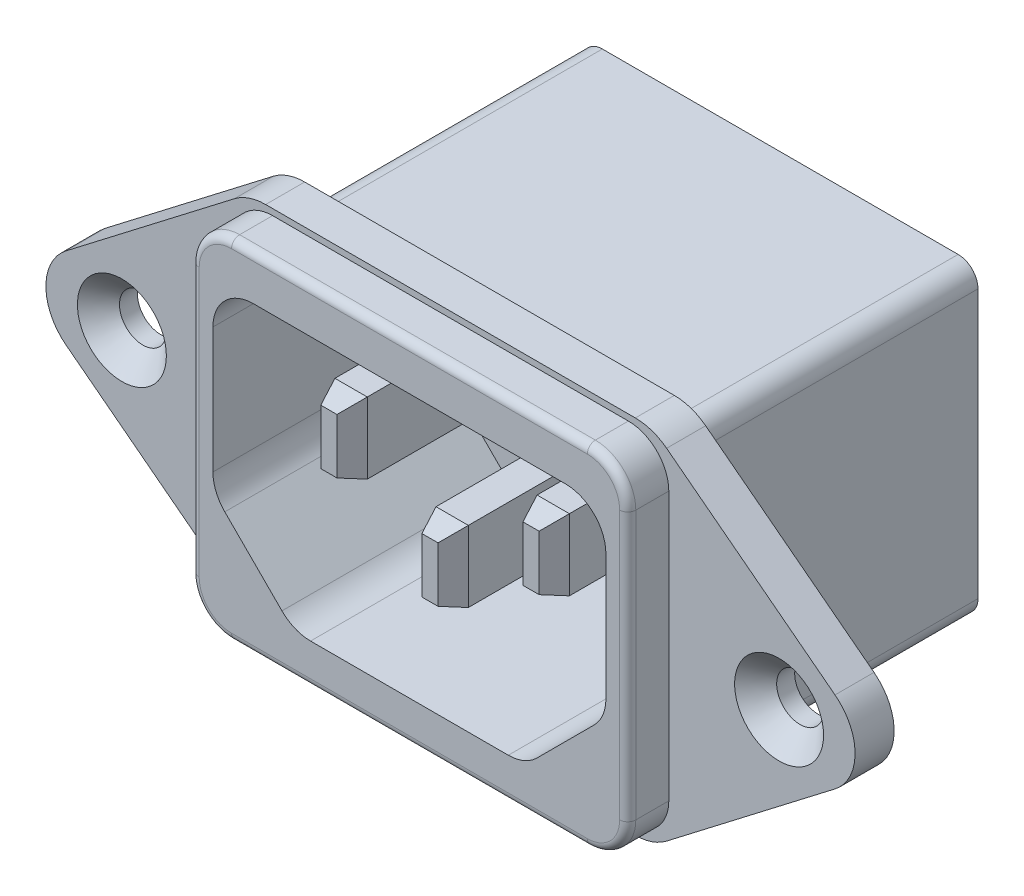
from build123d import *

# Parameters (mm, degrees)
EXTRUDE1_DEPTH                                    = 5.15
FILLET1_R                                         = 1
EXTRUDE2_DEPTH                                    = 17.78
EXTRUDE3_DEPTH                                    = 13.97
EXTRUDE4_DEPTH                                    = 3.81
FILLET2_R                                         = 2.5
SKETCH5_W                                         = 2
SKETCH5_H                                         = 4.4
EXTRUDE5_DEPTH                                    = 12.7
CHAMFER1_SIZE                                     = 0.5
CHAMFER1_SIZE2                                    = 1.37373871
CHAMFER1_PART_2_SIZE                              = 0.5
CHAMFER1_PART_2_SIZE2                             = 1.37373871
CHAMFER1_PART_3_SIZE                              = 0.5
CHAMFER1_PART_3_SIZE2                             = 1.37373871
CHAMFER2_SIZE                                     = 0.5
CHAMFER2_SIZE2                                    = 1.37373871
CHAMFER2_PART_2_SIZE                              = 0.5
CHAMFER2_PART_2_SIZE2                             = 1.37373871
CHAMFER2_PART_3_SIZE                              = 0.5
CHAMFER2_PART_3_SIZE2                             = 1.37373871
FILLET3_R                                         = 0.5
SKETCH10_OUTSIDE_W                                = 57.448
SKETCH10_OUTSIDE_H                                = 47.956
EXTRUDE10_DEPTH                                   = 20.12
SKETCH11_OUTSIDE_W                                = 37.296
SKETCH11_OUTSIDE_H                                = 31.886
EXTRUDE11_DEPTH                                   = 21.39
EXTRUDE12_DEPTH                                   = 2.413
CSK_FOR_M2_5_FLAT_HEAD_MACHINE_SCREW1_D           = 2.9
CSK_FOR_M2_5_FLAT_HEAD_MACHINE_SCREW1_CSINK_D     = 5.5
CSK_FOR_M2_5_FLAT_HEAD_MACHINE_SCREW1_CSINK_ANGLE = 90


with BuildPart() as part:
    # Sketch1 → Extrude1 (new body)
    with BuildSketch(Plane.XY):
        with BuildLine():
            Line((-13.6, 17), (13.6, 17))
            Line((13.6, 17), (21.429179607, 1.341640786))
            ThreePointArc((21.429179607, 1.341640786), (21.745898034, 0), (21.429179607, -1.341640786))
            Line((21.429179607, -1.341640786), (13.6, -17))
            Line((13.6, -17), (-13.6, -17))
            Line((-13.6, -17), (-21.429179607, -1.341640786))
            ThreePointArc((-21.429179607, -1.341640786), (-21.745898034, 0), (-21.429179607, 1.341640786))
            Line((-21.429179607, 1.341640786), (-13.6, 17))
        make_face()
    extrude(amount=-EXTRUDE1_DEPTH)

    # Fillet1
    fillet1_edges = [part.edges().sort_by_distance(p)[0] for p in [
        (-13.6, 17, -2.575),
        (13.6, 17, -2.575),
        (13.6, -17, -2.575),
        (-13.6, -17, -2.575),
    ]]
    fillet(fillet1_edges, radius=FILLET1_R)

    # Sketch2 → Extrude2 (add)
    with BuildSketch(Plane(origin=(0, 0, -5.15), x_dir=(-1, 0, 0), z_dir=(0, 0, -1))):
        with BuildLine():
            Line((-12.9, 15.65), (12.9, 15.65))
            ThreePointArc((12.9, 15.65), (13.607106781, 15.357106781), (13.9, 14.65))
            Line((13.9, 14.65), (13.9, -14.65))
            ThreePointArc((13.9, -14.65), (13.607106781, -15.357106781), (12.9, -15.65))
            Line((12.9, -15.65), (-12.9, -15.65))
            ThreePointArc((-12.9, -15.65), (-13.607106781, -15.357106781), (-13.9, -14.65))
            Line((-13.9, -14.65), (-13.9, 14.65))
            ThreePointArc((-13.9, 14.65), (-13.607106781, 15.357106781), (-12.9, 15.65))
        make_face()
    extrude(amount=EXTRUDE2_DEPTH)

    # Sketch3 → Extrude3 (cut)
    with BuildSketch(Plane.XY):
        Polygon((-12.15, -9.18), (-7.15, -14.18), (7.15, -14.18), (12.15, -9.18), (12.15, 2.12), (-12.15, 2.12), align=None)
    extrude(amount=-EXTRUDE3_DEPTH, mode=Mode.SUBTRACT)

    # Sketch4 → Extrude4 (cut)
    with BuildSketch(Plane.XY):
        with BuildLine():
            Line((-21.429179607, -1.341640786), (-13.876393202, -16.447213595))
            ThreePointArc((-13.876393202, -16.447213595), (-13.507697123, -16.850650808), (-12.981966011, -17))
            Line((-12.981966011, -17), (12.981966011, -17))
            ThreePointArc((12.981966011, -17), (13.507697123, -16.850650808), (13.876393202, -16.447213595))
            Line((13.876393202, -16.447213595), (21.429179607, -1.341640786))
            ThreePointArc((21.429179607, -1.341640786), (21.745898034, 0), (21.429179607, 1.341640786))
            Line((21.429179607, 1.341640786), (13.876393202, 16.447213595))
            ThreePointArc((13.876393202, 16.447213595), (13.507697123, 16.850650808), (12.981966011, 17))
            Line((12.981966011, 17), (-12.981966011, 17))
            ThreePointArc((-12.981966011, 17), (-13.507697123, 16.850650808), (-13.876393202, 16.447213595))
            Line((-13.876393202, 16.447213595), (-21.429179607, 1.341640786))
            ThreePointArc((-21.429179607, 1.341640786), (-21.745898034, 0), (-21.429179607, -1.341640786))
        make_face()
        with BuildLine():
            Line((-11, 4.8886), (11, 4.8886))
            ThreePointArc((11, 4.8886), (12.767766953, 4.156366953), (13.5, 2.3886))
            Line((13.5, 2.3886), (13.5, -14.2014))
            ThreePointArc((13.5, -14.2014), (12.767766953, -15.969166953), (11, -16.7014))
            Line((11, -16.7014), (-11, -16.7014))
            ThreePointArc((-11, -16.7014), (-12.767766953, -15.969166953), (-13.5, -14.2014))
            Line((-13.5, -14.2014), (-13.5, 2.3886))
            ThreePointArc((-13.5, 2.3886), (-12.767766953, 4.156366953), (-11, 4.8886))
        make_face(mode=Mode.SUBTRACT)
    extrude(amount=-EXTRUDE4_DEPTH, mode=Mode.SUBTRACT)

    # Fillet2
    fillet2_edges = [part.edges().sort_by_distance(p)[0] for p in [
        (-12.15, -9.18, -6.985),
        (-12.15, 2.12, -6.985),
        (12.15, 2.12, -6.985),
        (12.15, -9.18, -6.985),
        (7.15, -14.18, -6.985),
        (-7.15, -14.18, -6.985),
    ]]
    fillet(fillet2_edges, radius=FILLET2_R)

    # Sketch5 → Extrude5 (add)
    with BuildSketch(Plane.XY.offset(-13.97)):
        with Locations((-6.25, -4.2)):
            Rectangle(SKETCH5_W, SKETCH5_H)
        with Locations((0, -7.95)):
            Rectangle(SKETCH5_W, SKETCH5_H)
        with Locations((6.25, -4.2)):
            Rectangle(SKETCH5_W, SKETCH5_H)
    extrude(amount=EXTRUDE5_DEPTH)

    # Chamfer1
    chamfer1_edges = [part.edges().sort_by_distance(p)[0] for p in [
        (-6.25, -6.4, -1.27),
        (-6.25, -2, -1.27),
    ]]
    chamfer1_side = [part.faces().sort_by_distance(p)[0] for p in [
        (-6.25, -4.2, -1.27),
    ]]
    chamfer(chamfer1_edges, length=CHAMFER1_SIZE, length2=CHAMFER1_SIZE2, reference=chamfer1_side[0])

    # Chamfer1 part 2
    chamfer1_part_2_edges = [part.edges().sort_by_distance(p)[0] for p in [
        (0, -10.15, -1.27),
        (0, -5.75, -1.27),
    ]]
    chamfer1_part_2_side = [part.faces().sort_by_distance(p)[0] for p in [
        (0, -7.95, -1.27),
    ]]
    chamfer(chamfer1_part_2_edges, length=CHAMFER1_PART_2_SIZE, length2=CHAMFER1_PART_2_SIZE2, reference=chamfer1_part_2_side[0])

    # Chamfer1 part 3
    chamfer1_part_3_edges = [part.edges().sort_by_distance(p)[0] for p in [
        (6.25, -2, -1.27),
        (6.25, -6.4, -1.27),
    ]]
    chamfer1_part_3_side = [part.faces().sort_by_distance(p)[0] for p in [
        (6.25, -4.2, -1.27),
    ]]
    chamfer(chamfer1_part_3_edges, length=CHAMFER1_PART_3_SIZE, length2=CHAMFER1_PART_3_SIZE2, reference=chamfer1_part_3_side[0])

    # Chamfer2
    chamfer2_edges = [part.edges().sort_by_distance(p)[0] for p in [
        (7.25, -4.2, -1.27),
        (5.25, -4.2, -1.27),
    ]]
    chamfer2_side = [part.faces().sort_by_distance(p)[0] for p in [
        (6.25, -4.2, -1.27),
    ]]
    chamfer(chamfer2_edges, length=CHAMFER2_SIZE, length2=CHAMFER2_SIZE2, reference=chamfer2_side[0])

    # Chamfer2 part 2
    chamfer2_part_2_edges = [part.edges().sort_by_distance(p)[0] for p in [
        (1, -7.95, -1.27),
        (-1, -7.95, -1.27),
    ]]
    chamfer2_part_2_side = [part.faces().sort_by_distance(p)[0] for p in [
        (0, -7.95, -1.27),
    ]]
    chamfer(chamfer2_part_2_edges, length=CHAMFER2_PART_2_SIZE, length2=CHAMFER2_PART_2_SIZE2, reference=chamfer2_part_2_side[0])

    # Chamfer2 part 3
    chamfer2_part_3_edges = [part.edges().sort_by_distance(p)[0] for p in [
        (-7.25, -4.2, -1.27),
        (-5.25, -4.2, -1.27),
    ]]
    chamfer2_part_3_side = [part.faces().sort_by_distance(p)[0] for p in [
        (-6.25, -4.2, -1.27),
    ]]
    chamfer(chamfer2_part_3_edges, length=CHAMFER2_PART_3_SIZE, length2=CHAMFER2_PART_3_SIZE2, reference=chamfer2_part_3_side[0])

    # Fillet3
    fillet3_edges = [part.edges().sort_by_distance(p)[0] for p in [
        (-12.767766953, 4.156366953, 0),
        (0, 4.8886, 0),
        (12.767766953, 4.156366953, 0),
        (13.5, -5.9064, 0),
        (12.767766953, -15.969166953, 0),
        (0, -16.7014, 0),
        (-12.767766953, -15.969166953, 0),
        (-13.5, -5.9064, 0),
    ]]
    fillet(fillet3_edges, radius=FILLET3_R)

    # Sketch10 outside → Extrude10 (cut, through all)
    with BuildSketch(Plane.XY.offset(-3.81)):
        Rectangle(SKETCH10_OUTSIDE_W, SKETCH10_OUTSIDE_H)
        with BuildLine():
            Line((-13.5, 2.3886), (-13.5, -14.2014))
            ThreePointArc((-13.5, -14.2014), (-12.767766953, -15.969166953), (-11, -16.7014))
            Line((-11, -16.7014), (11, -16.7014))
            ThreePointArc((11, -16.7014), (12.767766953, -15.969166953), (13.5, -14.2014))
            Line((13.5, -14.2014), (13.5, 2.3886))
            ThreePointArc((13.5, 2.3886), (12.767766953, 4.156366953), (11, 4.8886))
            Line((11, 4.8886), (-11, 4.8886))
            ThreePointArc((-11, 4.8886), (-12.767766953, 4.156366953), (-13.5, 2.3886))
        make_face(mode=Mode.SUBTRACT)
    extrude(amount=-EXTRUDE10_DEPTH, mode=Mode.SUBTRACT)

    # Sketch11 outside → Extrude11 (cut, through all)
    with BuildSketch(Plane.XY.offset(-2.54)):
        with Locations((0, -5.906)):
            Rectangle(SKETCH11_OUTSIDE_W, SKETCH11_OUTSIDE_H)
        with BuildLine():
            Line((-11, -15.4314), (11, -15.4314))
            ThreePointArc((11, -15.4314), (11.869741341, -15.071141341), (12.23, -14.2014))
            Line((12.23, -14.2014), (12.23, 2.3886))
            ThreePointArc((12.23, 2.3886), (11.869741341, 3.258341341), (11, 3.6186))
            Line((11, 3.6186), (-11, 3.6186))
            ThreePointArc((-11, 3.6186), (-11.869741341, 3.258341341), (-12.23, 2.3886))
            Line((-12.23, 2.3886), (-12.23, -14.2014))
            ThreePointArc((-12.23, -14.2014), (-11.869741341, -15.071141341), (-11, -15.4314))
        make_face(mode=Mode.SUBTRACT)
    extrude(amount=-EXTRUDE11_DEPTH, mode=Mode.SUBTRACT)

    # Sketch12 → Extrude12 (add)
    with BuildSketch(Plane(origin=(0, 0, -2.54), x_dir=(-1, 0, 0), z_dir=(0, 0, -1))):
        with BuildLine():
            Line((-11.43, 5.2696), (11.43, 5.2696))
            ThreePointArc((11.43, 5.2696), (12.451483532, 5.100793007), (13.364347496, 4.612322138))
            Line((13.364347496, 4.612322138), (23.778347496, -3.388677862))
            ThreePointArc((23.778347496, -3.388677862), (25.019, -5.9064), (23.778347496, -8.424122138))
            Line((23.778347496, -8.424122138), (13.364347496, -16.425122138))
            ThreePointArc((13.364347496, -16.425122138), (12.451483532, -16.913593007), (11.43, -17.0824))
            Line((11.43, -17.0824), (-11.43, -17.0824))
            ThreePointArc((-11.43, -17.0824), (-12.451483532, -16.913593007), (-13.364347496, -16.425122138))
            Line((-13.364347496, -16.425122138), (-23.778347496, -8.424122138))
            ThreePointArc((-23.778347496, -8.424122138), (-25.019, -5.9064), (-23.778347496, -3.388677862))
            Line((-23.778347496, -3.388677862), (-13.364347496, 4.612322138))
            ThreePointArc((-13.364347496, 4.612322138), (-12.451483532, 5.100793007), (-11.43, 5.2696))
        make_face()
        with BuildLine():
            Line((12.23, 2.3886), (12.23, -14.2014))
            ThreePointArc((12.23, -14.2014), (11.869741341, -15.071141341), (11, -15.4314))
            Line((11, -15.4314), (-11, -15.4314))
            ThreePointArc((-11, -15.4314), (-11.869741341, -15.071141341), (-12.23, -14.2014))
            Line((-12.23, -14.2014), (-12.23, 2.3886))
            ThreePointArc((-12.23, 2.3886), (-11.869741341, 3.258341341), (-11, 3.6186))
            Line((-11, 3.6186), (11, 3.6186))
            ThreePointArc((11, 3.6186), (11.869741341, 3.258341341), (12.23, 2.3886))
        make_face(mode=Mode.SUBTRACT)
    extrude(amount=EXTRUDE12_DEPTH)

    # CSK for M2.5 Flat Head Machine Screw1 (through all)
    with Locations(Plane.XY.offset(-2.54)):
        with Locations((-20.32, -5.9064), (20.32, -5.9064)):
            CounterSinkHole(CSK_FOR_M2_5_FLAT_HEAD_MACHINE_SCREW1_D / 2, CSK_FOR_M2_5_FLAT_HEAD_MACHINE_SCREW1_CSINK_D / 2, counter_sink_angle=CSK_FOR_M2_5_FLAT_HEAD_MACHINE_SCREW1_CSINK_ANGLE)


solid = part.part
